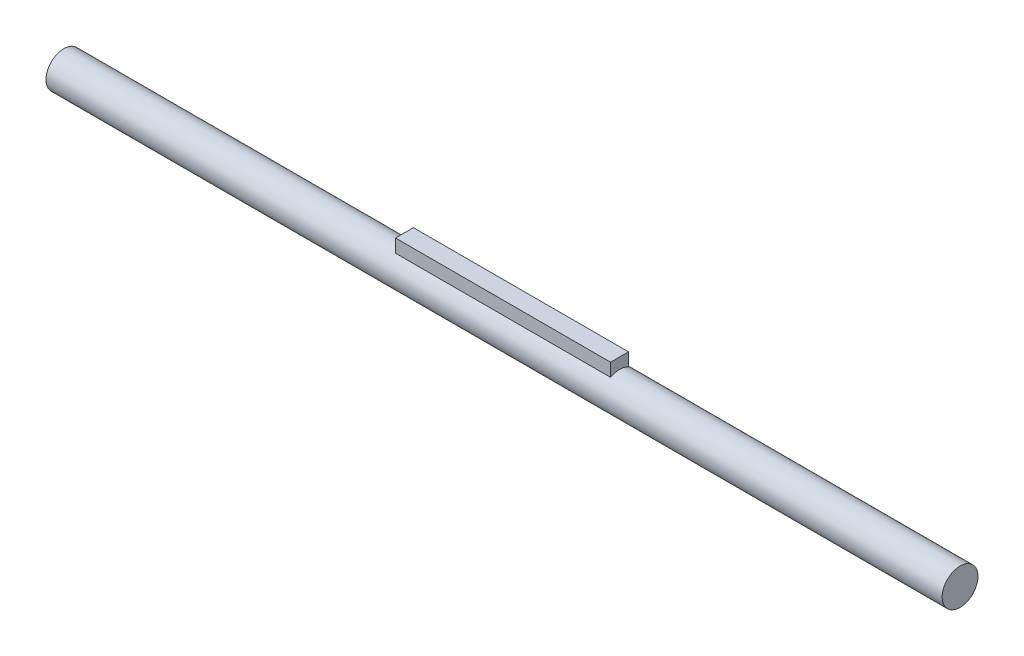
from build123d import *

# Parameters (mm, degrees)
SKETCH2_R                       = 5
SHAFT_DEPTH                     = 125
SHAFT_DEPTH_BACK                = 125
SKETCH3_W                       = 5
SKETCH3_H                       = 8
SHAFT_KEY_FOR_BICEPS_DEPTH      = 30
SHAFT_KEY_FOR_BICEPS_DEPTH_BACK = 30


with BuildPart() as part:
    # Sketch2 → Shaft (new body, two sides)
    with BuildSketch(Plane(origin=(0, 0, 0), x_dir=(0, 0, -1), z_dir=(1, 0, 0))) as shaft_sk:
        Circle(SKETCH2_R)
    extrude(amount=SHAFT_DEPTH)
    extrude(shaft_sk.sketch, amount=-SHAFT_DEPTH_BACK)

    # Sketch3 → Shaft Key for Biceps (add, two sides)
    with BuildSketch(Plane(origin=(0, 0, 0), x_dir=(0, 0, -1), z_dir=(1, 0, 0))) as shaft_key_for_biceps_sk:
        with Locations((0, 4)):
            Rectangle(SKETCH3_W, SKETCH3_H)
    extrude(amount=SHAFT_KEY_FOR_BICEPS_DEPTH)
    extrude(shaft_key_for_biceps_sk.sketch, amount=-SHAFT_KEY_FOR_BICEPS_DEPTH_BACK)


solid = part.part
